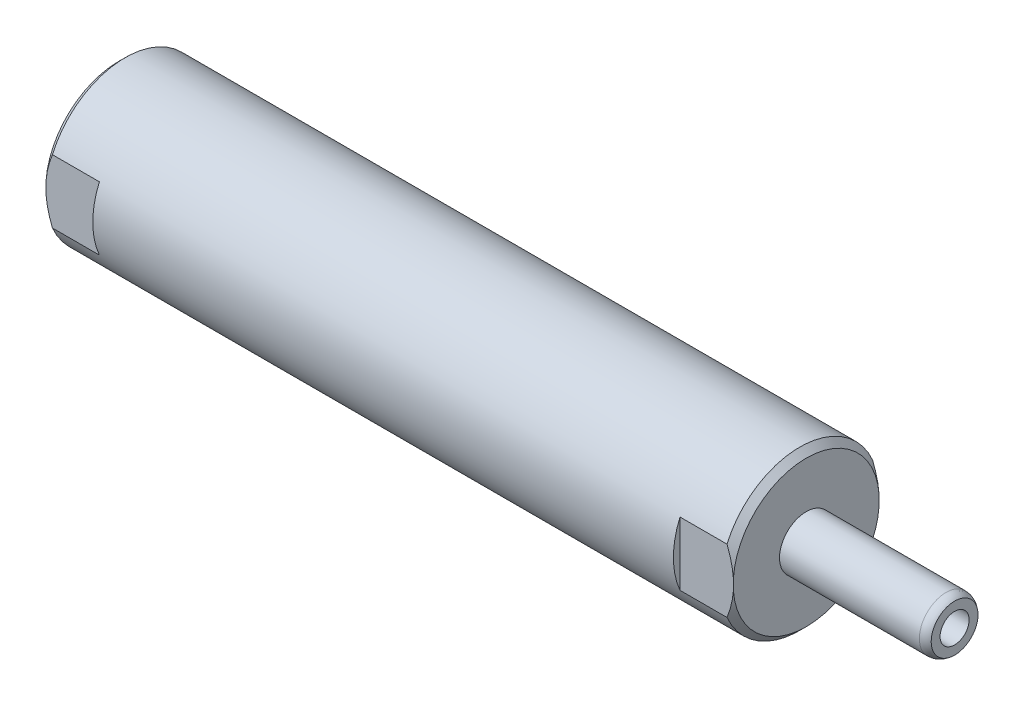
from build123d import *

# Parameters (mm, degrees)
CHAMFER1_SIZE           = 0.762
SKETCH5_W               = 6.35
SKETCH5_H               = 0.7874
CUT_EXTRUDE1_DEPTH      = 10.4488
CUT_EXTRUDE1_DEPTH_BACK = 10.4488
SKETCH6_W               = 6.35
SKETCH6_H               = 0.7874
CUT_EXTRUDE2_DEPTH      = 10.4488
CUT_EXTRUDE2_DEPTH_BACK = 10.4488


with BuildPart() as part:
    # Sketch1 → Revolve1 (revolve)
    with BuildSketch(Plane(origin=(0, 0, 0), x_dir=(-1, 0, 0), z_dir=(0, 0, -1)), mode=Mode.PRIVATE) as revolve1_sk:
        with BuildLine():
            Line((-99.4156, 2.786922533), (-99.4156, 0))
            Line((-99.4156, 0), (0, 0))
            Line((0, 0), (0, 9.4488))
            Line((0, 9.4488), (-81.7626, 9.4488))
            Line((-81.7626, 9.4488), (-81.7626, 3.175))
            Line((-81.7626, 3.175), (-98.3996, 3.175))
            ThreePointArc((-98.3996, 3.175), (-98.943396865, 3.074678675), (-99.4156, 2.786922533))
        make_face()
    revolve(revolve1_sk.sketch.rotate(Axis((99.4156, 0, 0), (-1, 0, 0)), 270), axis=Axis((99.4156, 0, 0), (-1, 0, 0)))  # turned: the seam where the file's is

    # Sketch2 → Cut-Revolve1 (revolve, cut)
    with BuildSketch(Plane(origin=(0, 0, 0), x_dir=(-1, 0, 0), z_dir=(0, 0, -1)), mode=Mode.PRIVATE) as cut_revolve1_sk:
        Polygon((-13.97, 4.9784), (-13.97, 0), (0, 0), (0, 6.1849), (-2.5527, 5.642306865), (-3.216606865, 4.9784), align=None)
    revolve(cut_revolve1_sk.sketch.rotate(Axis((13.97, 0, 0), (-1, 0, 0)), 270), axis=Axis((13.97, 0, 0), (-1, 0, 0)), mode=Mode.SUBTRACT)  # turned: the seam where the file's is

    # Sketch3 → Cut-Revolve2 (revolve, cut)
    with BuildSketch(Plane(origin=(0, 0, 0), x_dir=(-1, 0, 0), z_dir=(0, 0, -1)), mode=Mode.PRIVATE) as cut_revolve2_sk:
        Polygon((-99.4156, 1.7272), (-99.4156, 0), (-93.0656, 0), (-94.103406461, 1.7272), align=None)
    revolve(cut_revolve2_sk.sketch.rotate(Axis((66.313858967, 0, 0), (-1, 0, 0)), 270), axis=Axis((66.313858967, 0, 0), (-1, 0, 0)), mode=Mode.SUBTRACT)  # turned: the seam where the file's is

    # Chamfer1
    chamfer1_edges = [part.edges().sort_by_distance(p)[0] for p in [
        (81.7626, 0, -9.4488),
        (0, 0, -9.4488),
    ]]
    chamfer(chamfer1_edges, length=CHAMFER1_SIZE)

    # Sketch5 → Cut-Extrude1 (cut, two sides)
    with BuildSketch(Plane(origin=(0, 0, 0), x_dir=(1, 0, 0), z_dir=(0, 1, 0))) as cut_extrude1_sk:
        with Locations((3.175, 9.0551)):
            Rectangle(SKETCH5_W, SKETCH5_H)
        with Locations((3.175, -9.0551)):
            Rectangle(SKETCH5_W, SKETCH5_H)
    extrude(amount=CUT_EXTRUDE1_DEPTH, mode=Mode.SUBTRACT)
    extrude(cut_extrude1_sk.sketch, amount=-CUT_EXTRUDE1_DEPTH_BACK, mode=Mode.SUBTRACT)

    # Sketch6 → Cut-Extrude2 (cut, two sides)
    with BuildSketch(Plane(origin=(0, 0, 0), x_dir=(1, 0, 0), z_dir=(0, 1, 0))) as cut_extrude2_sk:
        with Locations((78.5876, 9.0551)):
            Rectangle(SKETCH6_W, SKETCH6_H)
        with Locations((78.5876, -9.0551)):
            Rectangle(SKETCH6_W, SKETCH6_H)
    extrude(amount=CUT_EXTRUDE2_DEPTH, mode=Mode.SUBTRACT)
    extrude(cut_extrude2_sk.sketch, amount=-CUT_EXTRUDE2_DEPTH_BACK, mode=Mode.SUBTRACT)


solid = part.part
